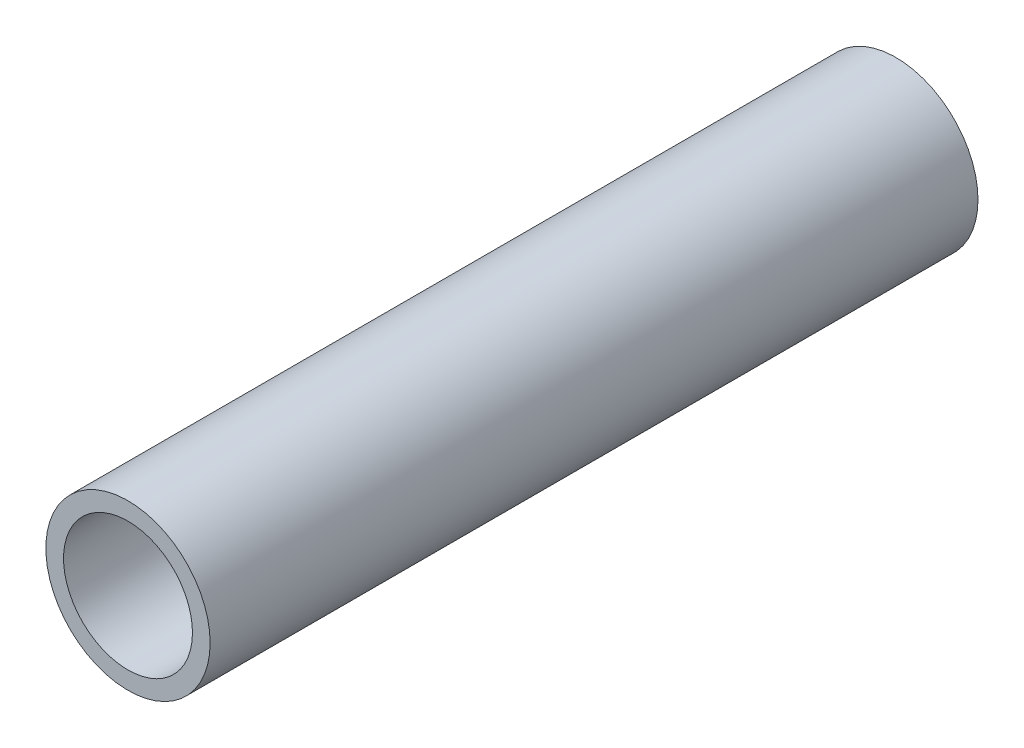
from build123d import *

# Parameters (mm, degrees)
SKETCH3_R                = 13.335
SKETCH3_R_2              = 10.4648
BOSS_EXTRUDE1_DEPTH      = 762
BOSS_EXTRUDE1_DEPTH_BACK = 762
SKETCH4_R                = 13.335
CUT_EXTRUDE2_DEPTH       = 1399.355469


with BuildPart() as part:
    # Sketch3 → Boss-Extrude1 (new body, two sides)
    with BuildSketch(Plane.XY) as boss_extrude1_sk:
        Circle(SKETCH3_R)
        Circle(SKETCH3_R_2, mode=Mode.SUBTRACT)
    extrude(amount=BOSS_EXTRUDE1_DEPTH)
    extrude(boss_extrude1_sk.sketch, amount=-BOSS_EXTRUDE1_DEPTH_BACK)

    # Sketch4 → Cut-Extrude2 (cut)
    with BuildSketch(Plane.XY.offset(762)):
        Circle(SKETCH4_R)
    extrude(amount=-CUT_EXTRUDE2_DEPTH, mode=Mode.SUBTRACT)


solid = part.part
